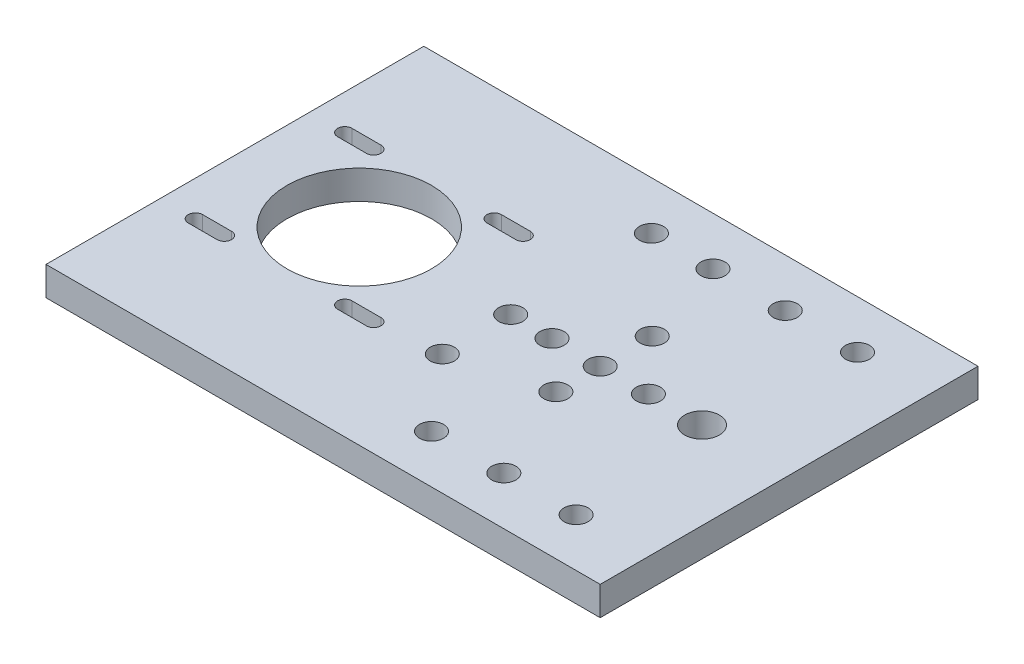
from build123d import *

# Parameters (mm, degrees)
BOSS_EXTRUDE1_DEPTH = 6
SKETCH1_7_R         = 2.5
SKETCH1_7_R_2       = 3.6
SKETCH1_7_R_3       = 15
CUT_EXTRUDE3_DEPTH  = 6


with BuildPart() as part:
    # Sketch1 → Boss-Extrude1 (new body)
    with BuildSketch(Plane(origin=(0, 0, 0), x_dir=(1, 0, 0), z_dir=(0, 1, 0))):
        Polygon((39.199236391, -39.199236391), (39.199236391, 39.199236391), (-75.800763609, 39.199236391), (-75.800763609, -39.199236391), (-39.199236391, -39.199236391), align=None)
    extrude(amount=BOSS_EXTRUDE1_DEPTH)

    # Sketch1_7 → Cut-Extrude3 (cut)
    with BuildSketch(Plane(origin=(0, 0, 0), x_dir=(1, 0, 0), z_dir=(0, 1, 0))):
        with Locations((-18.568778226, 29.199236391)):
            Circle(SKETCH1_7_R)
        with Locations((-18.568778226, -14.199236391)):
            Circle(SKETCH1_7_R)
        with Locations((24.199236391, 29.199236391)):
            Circle(SKETCH1_7_R)
        with Locations((9.199236391, 29.199236391)):
            Circle(SKETCH1_7_R)
        with Locations((21.131221774, 0)):
            Circle(SKETCH1_7_R_2)
        Circle(SKETCH1_7_R)
        with Locations((-10, 0)):
            Circle(SKETCH1_7_R)
        with Locations((-18.568778226, 0)):
            Circle(SKETCH1_7_R)
        with Locations((10, 0)):
            Circle(SKETCH1_7_R)
        with Locations((-5.800763609, 29.199236391)):
            Circle(SKETCH1_7_R)
        with Locations((-5.800763609, -29.199236391)):
            Circle(SKETCH1_7_R)
        with Locations((24.199236391, -29.199236391)):
            Circle(SKETCH1_7_R)
        with Locations((9.199236391, -29.199236391)):
            Circle(SKETCH1_7_R)
        with Locations((0, -9.199236391)):
            Circle(SKETCH1_7_R)
        with Locations((0, 10.800763609)):
            Circle(SKETCH1_7_R)
        with Locations((-50, 0)):
            Circle(SKETCH1_7_R_3)
        with BuildLine():
            Line((-68.5, 14), (-62.5, 14))
            ThreePointArc((-62.5, 14), (-61, 15.5), (-62.5, 17))
            Line((-62.5, 17), (-68.5, 17))
            ThreePointArc((-68.5, 17), (-70, 15.5), (-68.5, 14))
        make_face()
        with BuildLine():
            Line((-37.5, 14), (-31.5, 14))
            ThreePointArc((-31.5, 14), (-30, 15.5), (-31.5, 17))
            Line((-31.5, 17), (-37.5, 17))
            ThreePointArc((-37.5, 17), (-39, 15.5), (-37.5, 14))
        make_face()
        with BuildLine():
            Line((-37.5, -17), (-31.5, -17))
            ThreePointArc((-31.5, -17), (-30, -15.5), (-31.5, -14))
            Line((-31.5, -14), (-37.5, -14))
            ThreePointArc((-37.5, -14), (-39, -15.5), (-37.5, -17))
        make_face()
        with BuildLine():
            Line((-68.5, -17), (-62.5, -17))
            ThreePointArc((-62.5, -17), (-61, -15.5), (-62.5, -14))
            Line((-62.5, -14), (-68.5, -14))
            ThreePointArc((-68.5, -14), (-70, -15.5), (-68.5, -17))
        make_face()
    extrude(amount=CUT_EXTRUDE3_DEPTH, mode=Mode.SUBTRACT)


solid = part.part
